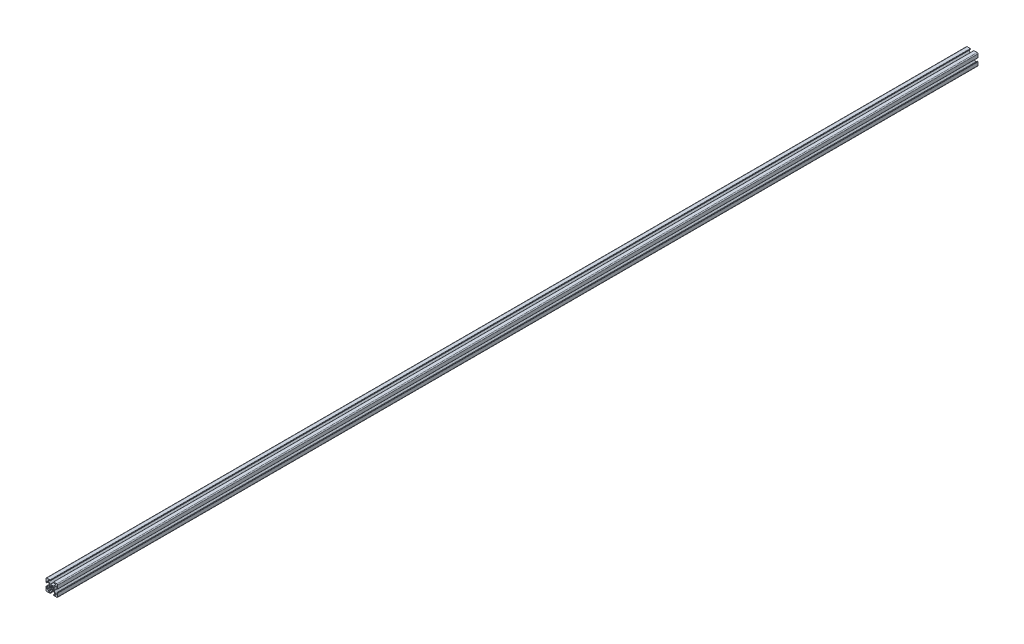
from build123d import *

# Parameters (mm, degrees)
BOSS_EXTRUDE1_DEPTH = 1567.18


with BuildPart() as part:
    # Sketch1 → Boss-Extrude1 (new body)
    with BuildSketch(Plane(origin=(0, 0, -457.2), x_dir=(-1, 0, 0), z_dir=(0, 0, -1))):
        with BuildLine():
            Line((10, -8.5), (10, -3.138))
            ThreePointArc((10, -3.138), (9.851210245, -2.778789755), (9.492, -2.63))
            Line((9.492, -2.63), (9.008, -2.63))
            ThreePointArc((9.008, -2.63), (8.648789755, -2.778789755), (8.5, -3.138))
            Line((8.5, -3.138), (8.5, -5.487))
            ThreePointArc((8.5, -5.487), (8.351210245, -5.846210245), (7.992, -5.995))
            Line((7.992, -5.995), (7.26592049, -5.995))
            ThreePointArc((7.26592049, -5.995), (7.071517306, -5.956330803), (6.906710245, -5.846210245))
            Line((6.906710245, -5.846210245), (3.803789755, -2.743289755))
            ThreePointArc((3.803789755, -2.743289755), (3.693669197, -2.578482694), (3.655, -2.38407951))
            Line((3.655, -2.38407951), (3.655, 2.383759167))
            ThreePointArc((3.655, 2.383759167), (3.693669197, 2.57816235), (3.803789755, 2.742969412))
            Line((3.803789755, 2.742969412), (6.907030588, 5.846210245))
            ThreePointArc((6.907030588, 5.846210245), (7.07183765, 5.956330803), (7.266240833, 5.995))
            Line((7.266240833, 5.995), (7.992, 5.995))
            ThreePointArc((7.992, 5.995), (8.351210245, 5.846210245), (8.5, 5.487))
            Line((8.5, 5.487), (8.5, 3.138))
            ThreePointArc((8.5, 3.138), (8.648789755, 2.778789755), (9.008, 2.63))
            Line((9.008, 2.63), (9.492, 2.63))
            ThreePointArc((9.492, 2.63), (9.851210245, 2.778789755), (10, 3.138))
            Line((10, 3.138), (10, 8.5))
            ThreePointArc((10, 8.5), (9.560660172, 9.560660172), (8.5, 10))
            Line((8.5, 10), (3.138, 10))
            ThreePointArc((3.138, 10), (2.778789755, 9.851210245), (2.63, 9.492))
            Line((2.63, 9.492), (2.63, 9.008))
            ThreePointArc((2.63, 9.008), (2.778789755, 8.648789755), (3.138, 8.5))
            Line((3.138, 8.5), (5.487, 8.5))
            ThreePointArc((5.487, 8.5), (5.846210245, 8.351210245), (5.995, 7.992))
            Line((5.995, 7.992), (5.995, 7.26592049))
            ThreePointArc((5.995, 7.26592049), (5.956330803, 7.071517306), (5.846210245, 6.906710245))
            Line((5.846210245, 6.906710245), (2.743289755, 3.803789755))
            ThreePointArc((2.743289755, 3.803789755), (2.578482694, 3.693669197), (2.38407951, 3.655))
            Line((2.38407951, 3.655), (-2.383759167, 3.655))
            ThreePointArc((-2.383759167, 3.655), (-2.57816235, 3.693669197), (-2.742969412, 3.803789755))
            Line((-2.742969412, 3.803789755), (-5.846210245, 6.907030588))
            ThreePointArc((-5.846210245, 6.907030588), (-5.956330803, 7.07183765), (-5.995, 7.266240833))
            Line((-5.995, 7.266240833), (-5.995, 7.992))
            ThreePointArc((-5.995, 7.992), (-5.846210245, 8.351210245), (-5.487, 8.5))
            Line((-5.487, 8.5), (-3.138, 8.5))
            ThreePointArc((-3.138, 8.5), (-2.778789755, 8.648789755), (-2.63, 9.008))
            Line((-2.63, 9.008), (-2.63, 9.492))
            ThreePointArc((-2.63, 9.492), (-2.778789755, 9.851210245), (-3.138, 10))
            Line((-3.138, 10), (-8.5, 10))
            ThreePointArc((-8.5, 10), (-9.560660172, 9.560660172), (-10, 8.5))
            Line((-10, 8.5), (-10, 3.138))
            ThreePointArc((-10, 3.138), (-9.851210245, 2.778789755), (-9.492, 2.63))
            Line((-9.492, 2.63), (-9.008, 2.63))
            ThreePointArc((-9.008, 2.63), (-8.648789755, 2.778789755), (-8.5, 3.138))
            Line((-8.5, 3.138), (-8.5, 5.487))
            ThreePointArc((-8.5, 5.487), (-8.351210245, 5.846210245), (-7.992, 5.995))
            Line((-7.992, 5.995), (-7.26592049, 5.995))
            ThreePointArc((-7.26592049, 5.995), (-7.071517306, 5.956330803), (-6.906710245, 5.846210245))
            Line((-6.906710245, 5.846210245), (-3.803789755, 2.743289755))
            ThreePointArc((-3.803789755, 2.743289755), (-3.693669197, 2.578482694), (-3.655, 2.38407951))
            Line((-3.655, 2.38407951), (-3.655, -2.383759167))
            ThreePointArc((-3.655, -2.383759167), (-3.693669197, -2.57816235), (-3.803789755, -2.742969412))
            Line((-3.803789755, -2.742969412), (-6.907030588, -5.846210245))
            ThreePointArc((-6.907030588, -5.846210245), (-7.07183765, -5.956330803), (-7.266240833, -5.995))
            Line((-7.266240833, -5.995), (-7.992, -5.995))
            ThreePointArc((-7.992, -5.995), (-8.351210245, -5.846210245), (-8.5, -5.487))
            Line((-8.5, -5.487), (-8.5, -3.138))
            ThreePointArc((-8.5, -3.138), (-8.648789755, -2.778789755), (-9.008, -2.63))
            Line((-9.008, -2.63), (-9.492, -2.63))
            ThreePointArc((-9.492, -2.63), (-9.851210245, -2.778789755), (-10, -3.138))
            Line((-10, -3.138), (-10, -8.5))
            ThreePointArc((-10, -8.5), (-9.560660172, -9.560660172), (-8.5, -10))
            Line((-8.5, -10), (-3.138, -10))
            ThreePointArc((-3.138, -10), (-2.778789755, -9.851210245), (-2.63, -9.492))
            Line((-2.63, -9.492), (-2.63, -9.008))
            ThreePointArc((-2.63, -9.008), (-2.778789755, -8.648789755), (-3.138, -8.5))
            Line((-3.138, -8.5), (-5.487, -8.5))
            ThreePointArc((-5.487, -8.5), (-5.846210245, -8.351210245), (-5.995, -7.992))
            Line((-5.995, -7.992), (-5.995, -7.26592049))
            ThreePointArc((-5.995, -7.26592049), (-5.956330803, -7.071517306), (-5.846210245, -6.906710245))
            Line((-5.846210245, -6.906710245), (-2.743289755, -3.803789755))
            ThreePointArc((-2.743289755, -3.803789755), (-2.578482694, -3.693669197), (-2.38407951, -3.655))
            Line((-2.38407951, -3.655), (2.383759167, -3.655))
            ThreePointArc((2.383759167, -3.655), (2.57816235, -3.693669197), (2.742969412, -3.803789755))
            Line((2.742969412, -3.803789755), (5.846210245, -6.907030588))
            ThreePointArc((5.846210245, -6.907030588), (5.956330803, -7.07183765), (5.995, -7.266240833))
            Line((5.995, -7.266240833), (5.995, -7.992))
            ThreePointArc((5.995, -7.992), (5.846210245, -8.351210245), (5.487, -8.5))
            Line((5.487, -8.5), (3.138, -8.5))
            ThreePointArc((3.138, -8.5), (2.778789755, -8.648789755), (2.63, -9.008))
            Line((2.63, -9.008), (2.63, -9.492))
            ThreePointArc((2.63, -9.492), (2.778789755, -9.851210245), (3.138, -10))
            Line((3.138, -10), (8.5, -10))
            ThreePointArc((8.5, -10), (9.560660172, -9.560660172), (10, -8.5))
        make_face()
        with BuildLine():
            Line((2.304493037, -2.124493037), (2.124493037, -2.304493037))
            ThreePointArc((2.124493037, -2.304493037), (1.35638567, -2.506016078), (0.803729988, -1.935777391))
            ThreePointArc((0.803729988, -1.935777391), (0, -2.096), (-0.803729988, -1.935777391))
            ThreePointArc((-0.803729988, -1.935777391), (-1.35638567, -2.506016078), (-2.124493037, -2.304493037))
            Line((-2.124493037, -2.304493037), (-2.304493037, -2.124493037))
            ThreePointArc((-2.304493037, -2.124493037), (-2.506016078, -1.35638567), (-1.935777391, -0.803729988))
            ThreePointArc((-1.935777391, -0.803729988), (-2.096, 0), (-1.935777391, 0.803729988))
            ThreePointArc((-1.935777391, 0.803729988), (-2.506016078, 1.35638567), (-2.304493037, 2.124493037))
            Line((-2.304493037, 2.124493037), (-2.124493037, 2.304493037))
            ThreePointArc((-2.124493037, 2.304493037), (-1.35638567, 2.506016078), (-0.803729988, 1.935777391))
            ThreePointArc((-0.803729988, 1.935777391), (0, 2.096), (0.803729988, 1.935777391))
            ThreePointArc((0.803729988, 1.935777391), (1.35638567, 2.506016078), (2.124493037, 2.304493037))
            Line((2.124493037, 2.304493037), (2.304493037, 2.124493037))
            ThreePointArc((2.304493037, 2.124493037), (2.506016078, 1.35638567), (1.935777391, 0.803729988))
            ThreePointArc((1.935777391, 0.803729988), (2.096, 0), (1.935777391, -0.803729988))
            ThreePointArc((1.935777391, -0.803729988), (2.506016078, -1.35638567), (2.304493037, -2.124493037))
        make_face(mode=Mode.SUBTRACT)
    extrude(amount=-BOSS_EXTRUDE1_DEPTH)


solid = part.part
